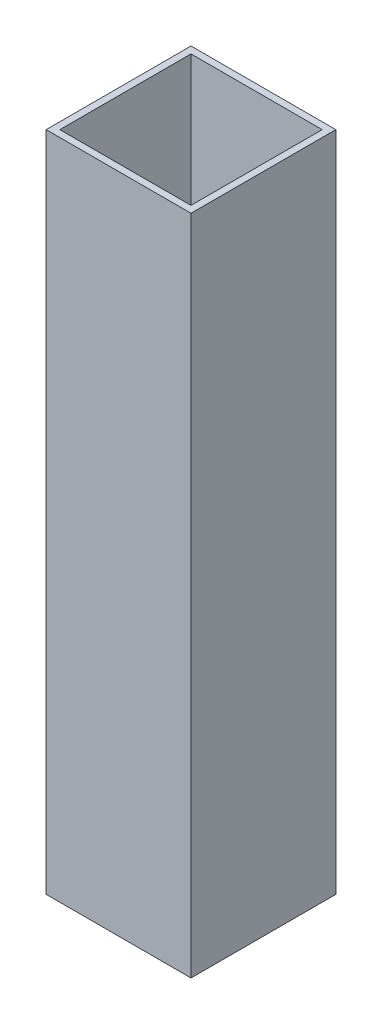
from build123d import *

# Parameters (mm, degrees)
SKETCH1_W           = 25.4
SKETCH1_H           = 25.4
SKETCH1_W_2         = 23
SKETCH1_H_2         = 23
BOSS_EXTRUDE1_DEPTH = 116.13


with BuildPart() as part:
    # Sketch1 → Boss-Extrude1 (new body)
    with BuildSketch(Plane(origin=(0, 0, 0), x_dir=(1, 0, 0), z_dir=(0, 1, 0))):
        with Locations((12.7, 12.7)):
            Rectangle(SKETCH1_W, SKETCH1_H)
        with Locations((12.7, 12.7)):
            Rectangle(SKETCH1_W_2, SKETCH1_H_2, mode=Mode.SUBTRACT)
    extrude(amount=BOSS_EXTRUDE1_DEPTH)


solid = part.part
